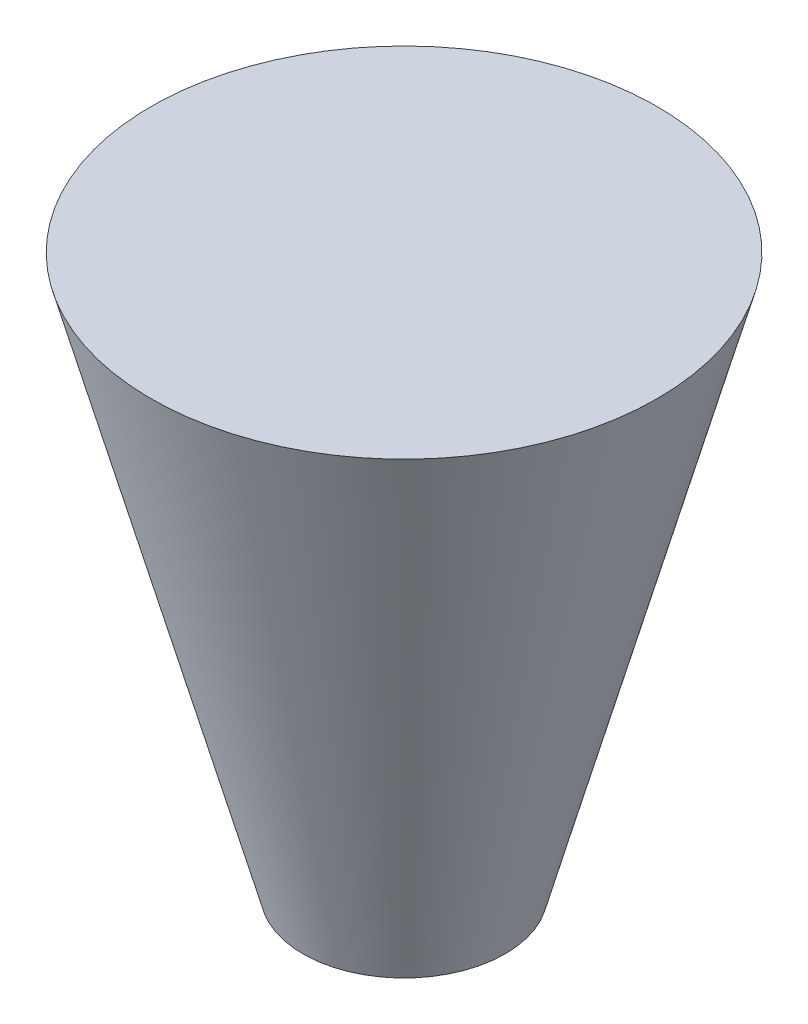
from build123d import *


with BuildPart() as part:
    # Sketch1 → Revolve1 (revolve)
    with BuildSketch(Plane.XY):
        Polygon((0, -50), (-20, -50), (-50, 60), (0, 60), align=None)
    revolve(axis=Axis((0, -50, 0), (0, 1, 0)))


solid = part.part
